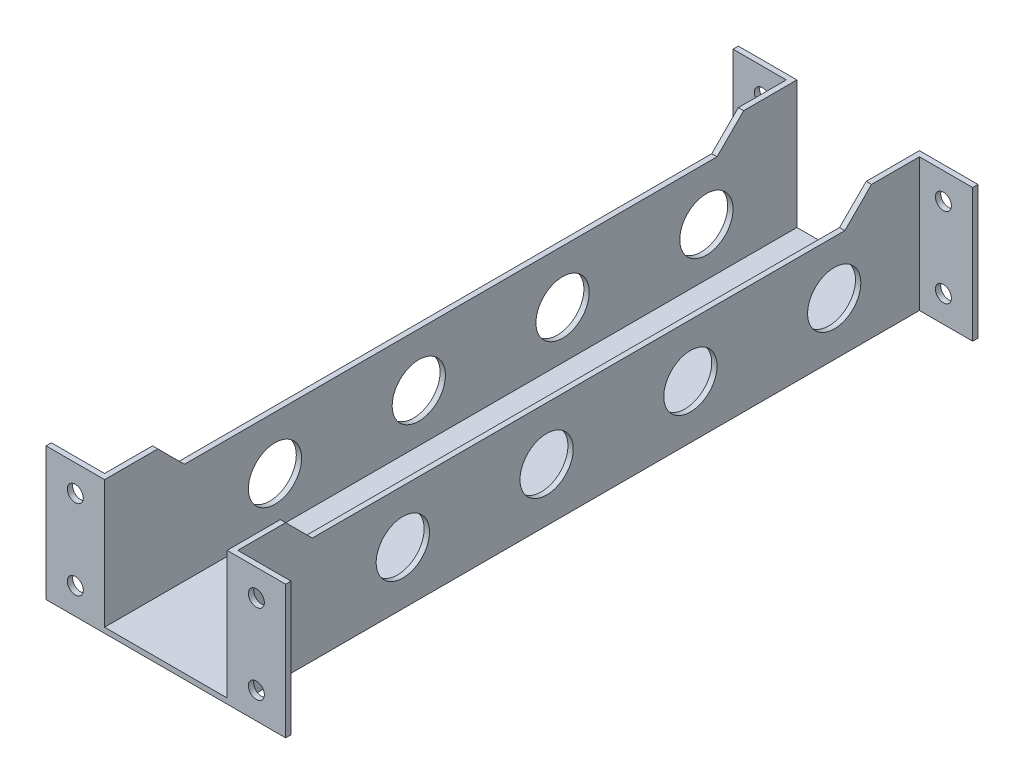
from build123d import *

# Parameters (mm, degrees)
SKETCH1_W               = 25
SKETCH1_H               = 130
BOSS_EXTRUDE1_DEPTH     = 1
SKETCH2_W               = 1
SKETCH2_H               = 130
BOSS_EXTRUDE2_DEPTH     = 24
SKETCH3_W               = 1
SKETCH3_H               = 25
BOSS_EXTRUDE3_DEPTH     = 10
SKETCH4_W               = 1
SKETCH4_H               = 25
BOSS_EXTRUDE4_DEPTH     = 10
SKETCH5_R               = 5
CUT_EXTRUDE1_DEPTH      = 2
SKETCH10_R              = 1.5
CUT_EXTRUDE3_DEPTH      = 131
CUT_EXTRUDE4_DEPTH      = 11
CUT_EXTRUDE4_DEPTH_BACK = 36
SKETCH9_R               = 5
CUT_EXTRUDE2_DEPTH      = 36


with BuildPart() as part:
    # Sketch1 → Boss-Extrude1 (new body)
    with BuildSketch(Plane(origin=(0, 0, 0), x_dir=(1, 0, 0), z_dir=(0, 1, 0))):
        Rectangle(SKETCH1_W, SKETCH1_H)
    extrude(amount=BOSS_EXTRUDE1_DEPTH)

    # Sketch2 → Boss-Extrude2 (add)
    with BuildSketch(Plane(origin=(0, 1, 0), x_dir=(1, 0, 0), z_dir=(0, 1, 0))):
        with Locations((12, 0)):
            Rectangle(SKETCH2_W, SKETCH2_H)
        with Locations((-12, 0)):
            Rectangle(SKETCH2_W, SKETCH2_H)
    extrude(amount=BOSS_EXTRUDE2_DEPTH)

    # Sketch3 → Boss-Extrude3 (add)
    with BuildSketch(Plane(origin=(12.5, 0, 0), x_dir=(0, 0, -1), z_dir=(1, 0, 0))):
        with Locations((-64.5, 12.5)):
            Rectangle(SKETCH3_W, SKETCH3_H)
        with Locations((64.5, 12.5)):
            Rectangle(SKETCH3_W, SKETCH3_H)
    extrude(amount=BOSS_EXTRUDE3_DEPTH)

    # Sketch4 → Boss-Extrude4 (add)
    with BuildSketch(Plane.ZY.offset(12.5)):
        with Locations((-64.5, 12.5)):
            Rectangle(SKETCH4_W, SKETCH4_H)
        with Locations((64.5, 12.5)):
            Rectangle(SKETCH4_W, SKETCH4_H)
    extrude(amount=BOSS_EXTRUDE4_DEPTH)

    # Sketch5 → Cut-Extrude1 (cut, through all)
    with BuildSketch(Plane(origin=(0, 1, 0), x_dir=(1, 0, 0), z_dir=(0, 1, 0))):
        with Locations((0, -33)):
            Circle(SKETCH5_R)
        with Locations((0, -6)):
            Circle(SKETCH5_R)
        with Locations((0, 21)):
            Circle(SKETCH5_R)
        with Locations((0, 48)):
            Circle(SKETCH5_R)
    extrude(amount=-CUT_EXTRUDE1_DEPTH, mode=Mode.SUBTRACT)

    # Sketch10 → Cut-Extrude3 (cut, through all)
    with BuildSketch(Plane.XY.offset(65)):
        with Locations((17, 20)):
            Circle(SKETCH10_R)
        with Locations((17, 5)):
            Circle(SKETCH10_R)
        with Locations((-17, 20)):
            Circle(SKETCH10_R)
        with Locations((-17, 5)):
            Circle(SKETCH10_R)
    extrude(amount=-CUT_EXTRUDE3_DEPTH, mode=Mode.SUBTRACT)

    # Sketch11 → Cut-Extrude4 (cut, two sides)
    with BuildSketch(Plane(origin=(12.5, 0, 0), x_dir=(0, 0, -1), z_dir=(1, 0, 0))) as cut_extrude4_sk:
        Polygon((0, 25), (-55, 25), (-50, 20), (0, 20), align=None)
        Polygon((55, 25), (0, 25), (0, 20), (50, 20), align=None)
    extrude(amount=CUT_EXTRUDE4_DEPTH, mode=Mode.SUBTRACT)
    extrude(cut_extrude4_sk.sketch, amount=-CUT_EXTRUDE4_DEPTH_BACK, mode=Mode.SUBTRACT)

    # Sketch9 → Cut-Extrude2 (cut, through all)
    with BuildSketch(Plane(origin=(12.5, 0, 0), x_dir=(0, 0, -1), z_dir=(1, 0, 0))):
        with Locations((-33, 10)):
            Circle(SKETCH9_R)
        with Locations((-6, 10)):
            Circle(SKETCH9_R)
        with Locations((21, 10)):
            Circle(SKETCH9_R)
        with Locations((48, 10)):
            Circle(SKETCH9_R)
    extrude(amount=-CUT_EXTRUDE2_DEPTH, mode=Mode.SUBTRACT)


solid = part.part
